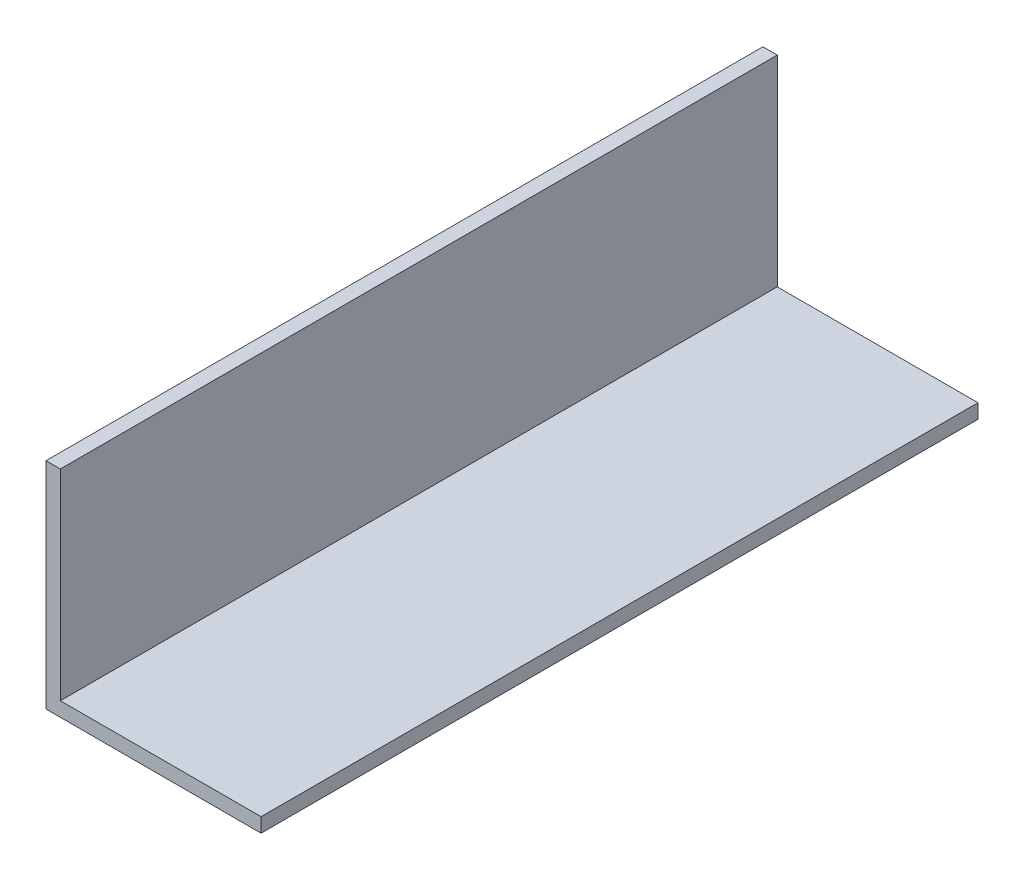
from build123d import *

# Parameters (mm, degrees)
EXTRUDE_1_DEPTH = 50


with BuildPart() as part:
    # ｽｹｯﾁ1 → ﾎﾞｽ - 押し出し1 (new body)
    with BuildSketch(Plane.XY):
        Polygon((-4.461455774, 6.353305785), (-5.461455774, 6.353305785), (-5.461455774, -8.646694215), (9.538544226, -8.646694215), (9.538544226, -7.646694215), (-4.461455774, -7.646694215), align=None)
    extrude(amount=EXTRUDE_1_DEPTH)


solid = part.part
